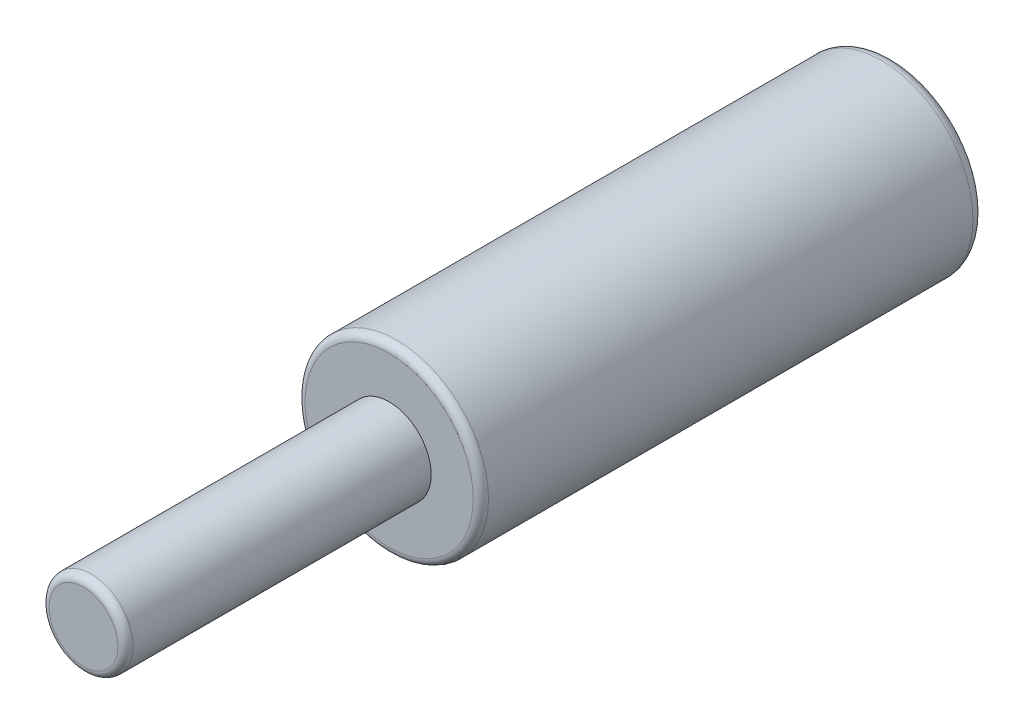
from build123d import *

# Parameters (mm, degrees)
CROQUIS1_R              = 6
CROQUIS1_R_2            = 3.5
SALIENTE_EXTRUIR1_DEPTH = 28
CROQUIS2_R              = 6
SALIENTE_EXTRUIR2_DEPTH = 5
CROQUIS3_R              = 2.75
SALIENTE_EXTRUIR3_DEPTH = 20
REDONDEO1_R             = 0.5
REDONDEO2_R             = 0.8
REDONDEO3_R             = 0.5


with BuildPart() as part:
    # Croquis1 → Saliente-Extruir1 (new body)
    with BuildSketch(Plane.XY):
        Circle(CROQUIS1_R)
        Circle(CROQUIS1_R_2, mode=Mode.SUBTRACT)
    extrude(amount=SALIENTE_EXTRUIR1_DEPTH)

    # Croquis2 → Saliente-Extruir2 (add)
    with BuildSketch(Plane.XY.offset(28)):
        Circle(CROQUIS2_R)
    extrude(amount=SALIENTE_EXTRUIR2_DEPTH)

    # Croquis3 → Saliente-Extruir3 (add)
    with BuildSketch(Plane.XY.offset(33)):
        Circle(CROQUIS3_R)
    extrude(amount=SALIENTE_EXTRUIR3_DEPTH)

    # Redondeo1
    redondeo1_edges = [part.edges().sort_by_distance(p)[0] for p in [
        (-6, 0, 33),
    ]]
    fillet(redondeo1_edges, radius=REDONDEO1_R)

    # Redondeo2
    redondeo2_edges = [part.edges().sort_by_distance(p)[0] for p in [
        (-6, 0, 0),
    ]]
    fillet(redondeo2_edges, radius=REDONDEO2_R)

    # Redondeo3
    redondeo3_edges = [part.edges().sort_by_distance(p)[0] for p in [
        (-2.75, 0, 53),
    ]]
    fillet(redondeo3_edges, radius=REDONDEO3_R)


solid = part.part
